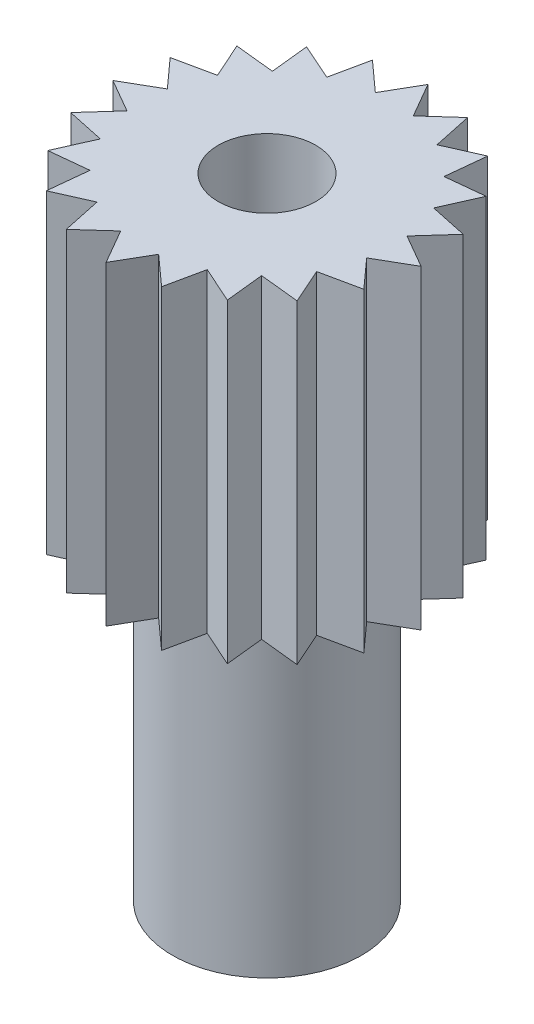
from build123d import *

# Parameters (mm, degrees)
SKETCH1_R           = 7
SKETCH1_R_2         = 3
BOSS_EXTRUDE1_DEPTH = 20
SKETCH2_R           = 10
SKETCH2_R_2         = 3
BOSS_EXTRUDE2_DEPTH = 20
CUT_EXTRUDE2_DEPTH  = 20
SKETCH4_R           = 21.655225415
SKETCH4_R_2         = 6
CUT_EXTRUDE3_DEPTH  = 20
SKETCH6_R           = 3.1
CUT_EXTRUDE4_DEPTH  = 80


with BuildPart() as part:
    # Sketch1 → Boss-Extrude1 (new body)
    with BuildSketch(Plane(origin=(0, 0, 0), x_dir=(1, 0, 0), z_dir=(0, 1, 0))):
        with Locations(Location((0, 0, 0), (0, 0, 270))):  # turned: the seam where the file's is
            Circle(SKETCH1_R)
        with Locations(Location((0, 0, 0), (0, 0, 270))):  # turned: the seam where the file's is
            Circle(SKETCH1_R_2, mode=Mode.SUBTRACT)
    extrude(amount=BOSS_EXTRUDE1_DEPTH)

    # Sketch2 → Boss-Extrude2 (add)
    with BuildSketch(Plane(origin=(0, 20, 0), x_dir=(1, 0, 0), z_dir=(0, 1, 0))):
        with Locations(Location((0, 0, 0), (0, 0, 270))):  # turned: the seam where the file's is
            Circle(SKETCH2_R)
        with Locations(Location((0, 0, 0), (0, 0, 270))):  # turned: the seam where the file's is
            Circle(SKETCH2_R_2, mode=Mode.SUBTRACT)
    extrude(amount=BOSS_EXTRUDE2_DEPTH)

    # Sketch3 → Cut-Extrude2 (cut)
    with BuildSketch(Plane(origin=(0, 40, 0), x_dir=(1, 0, 0), z_dir=(0, 1, 0))):
        with BuildLine():
            Line((1.481181144, 7.809519004), (3.294093052, 9.441872217))
            ThreePointArc((3.294093052, 9.441872217), (1.777835424, 9.840696175), (0.217876864, 9.997626202))
            Line((0.217876864, 9.997626202), (1.481181144, 7.809519004))
        make_face()
        with BuildLine():
            ThreePointArc((6.050567636, 7.961823364), (4.731764319, 8.809676863), (3.296649611, 9.440979893))
            Line((3.296649611, 9.440979893), (3.821961069, 6.969583792))
            Line((3.821961069, 6.969583792), (6.050567636, 7.961823364))
        make_face()
        with BuildLine():
            Line((-1.004587111, 7.885004083), (0.215169688, 9.997684832))
            ThreePointArc((0.215169688, 9.997684832), (-1.35012039, 9.908439581), (-2.882223189, 9.5756352))
            Line((-2.882223189, 9.5756352), (-1.004587111, 7.885004083))
        make_face()
        with BuildLine():
            ThreePointArc((8.214770503, 5.702415767), (7.222515155, 6.916304999), (6.052723325, 7.960184693))
            Line((6.052723325, 7.960184693), (5.788620815, 5.447417159))
            Line((5.788620815, 5.447417159), (8.214770503, 5.702415767))
        make_face()
        with BuildLine():
            Line((-3.392019381, 7.188650024), (-2.884815983, 9.574854398))
            ThreePointArc((-2.884815983, 9.574854398), (-4.345917013, 9.006275885), (-5.700191154, 8.216314308))
            Line((-5.700191154, 8.216314308), (-3.392019381, 7.188650024))
        make_face()
        with BuildLine():
            ThreePointArc((9.574854398, 2.884815983), (9.006275885, 4.345917013), (8.216314308, 5.700191154))
            Line((8.216314308, 5.700191154), (7.188650024, 3.392019381))
            Line((7.188650024, 3.392019381), (9.574854398, 2.884815983))
        make_face()
        with BuildLine():
            Line((-5.447417159, 5.788620815), (-5.702415767, 8.214770503))
            ThreePointArc((-5.702415767, 8.214770503), (-6.916304999, 7.222515155), (-7.960184693, 6.052723325))
            Line((-7.960184693, 6.052723325), (-5.447417159, 5.788620815))
        make_face()
        with BuildLine():
            ThreePointArc((9.997684832, -0.215169688), (9.908439581, 1.35012039), (9.5756352, 2.882223189))
            Line((9.5756352, 2.882223189), (7.885004083, 1.004587111))
            Line((7.885004083, 1.004587111), (9.997684832, -0.215169688))
        make_face()
        with BuildLine():
            Line((-6.969583792, 3.821961069), (-7.961823364, 6.050567636))
            ThreePointArc((-7.961823364, 6.050567636), (-8.809676863, 4.731764319), (-9.440979893, 3.296649611))
            Line((-9.440979893, 3.296649611), (-6.969583792, 3.821961069))
        make_face()
        with BuildLine():
            ThreePointArc((9.441872217, -3.294093052), (9.840696175, -1.777835424), (9.997626202, -0.217876864))
            Line((9.997626202, -0.217876864), (7.809519004, -1.481181144))
            Line((7.809519004, -1.481181144), (9.441872217, -3.294093052))
        make_face()
        with BuildLine():
            Line((-7.809519004, 1.481181144), (-9.441872217, 3.294093052))
            ThreePointArc((-9.441872217, 3.294093052), (-9.840696175, 1.777835424), (-9.997626202, 0.217876864))
            Line((-9.997626202, 0.217876864), (-7.809519004, 1.481181144))
        make_face()
        with BuildLine():
            ThreePointArc((7.961823364, -6.050567636), (8.809676863, -4.731764319), (9.440979893, -3.296649611))
            Line((9.440979893, -3.296649611), (6.969583792, -3.821961069))
            Line((6.969583792, -3.821961069), (7.961823364, -6.050567636))
        make_face()
        with BuildLine():
            Line((-7.885004083, -1.004587111), (-9.997684832, 0.215169688))
            ThreePointArc((-9.997684832, 0.215169688), (-9.908439581, -1.35012039), (-9.5756352, -2.882223189))
            Line((-9.5756352, -2.882223189), (-7.885004083, -1.004587111))
        make_face()
        with BuildLine():
            ThreePointArc((5.702415767, -8.214770503), (6.916304999, -7.222515155), (7.960184693, -6.052723325))
            Line((7.960184693, -6.052723325), (5.447417159, -5.788620815))
            Line((5.447417159, -5.788620815), (5.702415767, -8.214770503))
        make_face()
        with BuildLine():
            Line((-7.188650024, -3.392019381), (-9.574854398, -2.884815983))
            ThreePointArc((-9.574854398, -2.884815983), (-9.006275885, -4.345917013), (-8.216314308, -5.700191154))
            Line((-8.216314308, -5.700191154), (-7.188650024, -3.392019381))
        make_face()
        with BuildLine():
            ThreePointArc((2.884815983, -9.574854398), (4.345917013, -9.006275885), (5.700191154, -8.216314308))
            Line((5.700191154, -8.216314308), (3.392019381, -7.188650024))
            Line((3.392019381, -7.188650024), (2.884815983, -9.574854398))
        make_face()
        with BuildLine():
            Line((-5.788620815, -5.447417159), (-8.214770503, -5.702415767))
            ThreePointArc((-8.214770503, -5.702415767), (-7.222515155, -6.916304999), (-6.052723325, -7.960184693))
            Line((-6.052723325, -7.960184693), (-5.788620815, -5.447417159))
        make_face()
        with BuildLine():
            ThreePointArc((-0.215169688, -9.997684832), (1.35012039, -9.908439581), (2.882223189, -9.5756352))
            Line((2.882223189, -9.5756352), (1.004587111, -7.885004083))
            Line((1.004587111, -7.885004083), (-0.215169688, -9.997684832))
        make_face()
        with BuildLine():
            Line((-3.821961069, -6.969583792), (-6.050567636, -7.961823364))
            ThreePointArc((-6.050567636, -7.961823364), (-4.731764319, -8.809676863), (-3.296649611, -9.440979893))
            Line((-3.296649611, -9.440979893), (-3.821961069, -6.969583792))
        make_face()
        with BuildLine():
            ThreePointArc((-3.294093052, -9.441872217), (-1.777835424, -9.840696175), (-0.217876864, -9.997626202))
            Line((-0.217876864, -9.997626202), (-1.481181144, -7.809519004))
            Line((-1.481181144, -7.809519004), (-3.294093052, -9.441872217))
        make_face()
    extrude(amount=-CUT_EXTRUDE2_DEPTH, mode=Mode.SUBTRACT)

    # Sketch4 → Cut-Extrude3 (cut)
    with BuildSketch(Plane(origin=(0, 0, 0), x_dir=(-1, 0, 0), z_dir=(0, -1, 0))):
        with Locations((3.244661678, 1.192157737)):
            Circle(SKETCH4_R)
        with Locations(Location((0, 0, 0), (0, 0, 90))):  # turned: the seam where the file's is
            Circle(SKETCH4_R_2, mode=Mode.SUBTRACT)
    extrude(amount=-CUT_EXTRUDE3_DEPTH, mode=Mode.SUBTRACT)

    # Sketch6 → Cut-Extrude4 (cut)
    with BuildSketch(Plane(origin=(0, 0, 0), x_dir=(-1, 0, 0), z_dir=(0, -1, 0))):
        with Locations(Location((0, 0, 0), (0, 0, 90))):  # turned: the seam where the file's is
            Circle(SKETCH6_R)
    extrude(amount=-CUT_EXTRUDE4_DEPTH, mode=Mode.SUBTRACT)


solid = part.part
